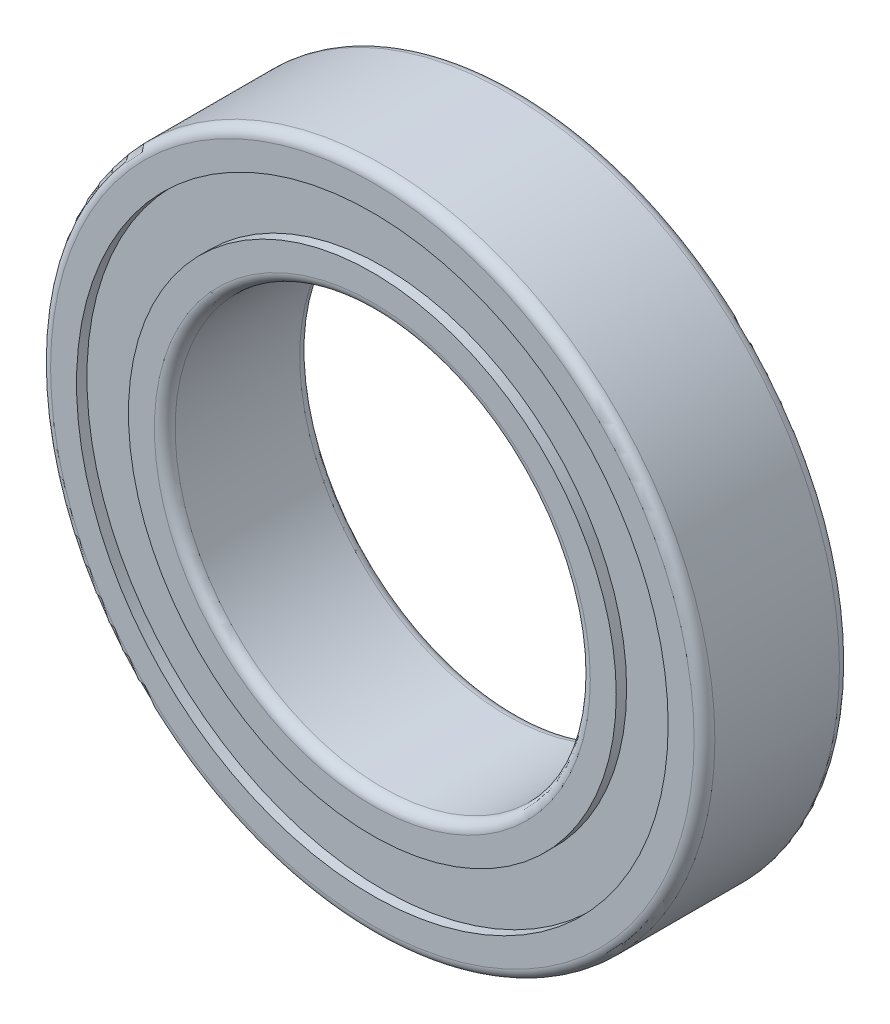
from build123d import *

# Parameters (mm, degrees)
SKETCH1_R           = 16
SKETCH1_R_2         = 10
BOSS_EXTRUDE1_DEPTH = 7
FILLET1_R           = 0.5
SKETCH2_R           = 14.25
SKETCH2_R_2         = 11.75
CUT_EXTRUDE1_DEPTH  = 0.5
SKETCH3_R           = 14.25
SKETCH3_R_2         = 11.75
CUT_EXTRUDE2_DEPTH  = 0.5


with BuildPart() as part:
    # Sketch1 → Boss-Extrude1 (new body)
    with BuildSketch(Plane.XY):
        with Locations((80, 28.257283518)):
            Circle(SKETCH1_R)
        with Locations((80, 28.257283518)):
            Circle(SKETCH1_R_2, mode=Mode.SUBTRACT)
    extrude(amount=BOSS_EXTRUDE1_DEPTH)

    # Fillet1
    fillet1_edges = [part.edges().sort_by_distance(p)[0] for p in [
        (64, 28.257283518, 0),
        (64, 28.257283518, 7),
        (70, 28.257283518, 0),
        (70, 28.257283518, 7),
    ]]
    fillet(fillet1_edges, radius=FILLET1_R)

    # Sketch2 → Cut-Extrude1 (cut)
    with BuildSketch(Plane(origin=(0, 0, 0), x_dir=(-1, 0, 0), z_dir=(0, 0, -1))):
        with Locations((-80, 28.257283518)):
            Circle(SKETCH2_R)
        with Locations((-80, 28.257283518)):
            Circle(SKETCH2_R_2, mode=Mode.SUBTRACT)
    extrude(amount=-CUT_EXTRUDE1_DEPTH, mode=Mode.SUBTRACT)

    # Sketch3 → Cut-Extrude2 (cut)
    with BuildSketch(Plane.XY.offset(7)):
        with Locations((80, 28.257283518)):
            Circle(SKETCH3_R)
        with Locations((80, 28.257283518)):
            Circle(SKETCH3_R_2, mode=Mode.SUBTRACT)
    extrude(amount=-CUT_EXTRUDE2_DEPTH, mode=Mode.SUBTRACT)


solid = part.part
